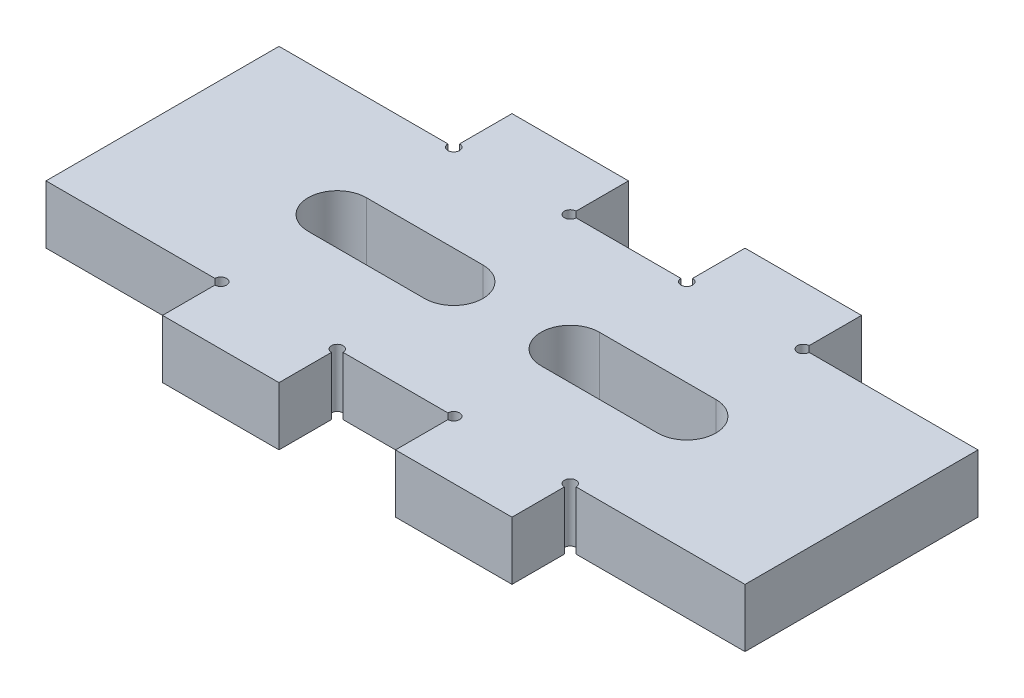
from build123d import *

# Parameters (mm, degrees)
BOSS_EXTRUDE1_DEPTH = 6.35
CUT_EXTRUDE1_REACH  = 45.068
SKETCH2_R           = 3.175
CUT_EXTRUDE2_START  = -6.35
SKETCH4_R           = 0.635
CUT_EXTRUDE2_DEPTH  = 6.35
CUT_EXTRUDE3_START  = -6.35
CUT_EXTRUDE3_DEPTH  = 6.35


with BuildPart() as part:
    # Sketch1 → Boss-Extrude1 (new body)
    with BuildSketch(Plane(origin=(0, 0, 0), x_dir=(1, 0, 0), z_dir=(0, 1, 0))):
        Polygon((-19.05, 12.7), (-19.05, 19.05), (-6.35, 19.05), (-6.35, 12.7), (6.35, 12.7), (6.35, 19.05), (19.05, 19.05), (19.05, 12.7), (38.1, 12.7), (38.1, -12.7), (19.05, -12.7), (19.05, -19.05), (6.35, -19.05), (6.35, -12.7), (-6.35, -12.7), (-6.35, -19.05), (-19.05, -19.05), (-19.05, -12.7), (-38.1, -12.7), (-38.1, 12.7), align=None)
    extrude(amount=BOSS_EXTRUDE1_DEPTH)

    # Sketch2 → Cut-Extrude1 (cut, up to next)
    with BuildSketch(Plane(origin=(0, 6.35, 0), x_dir=(1, 0, 0), z_dir=(0, 1, 0)), mode=Mode.PRIVATE) as cut_extrude1_sk1:
        with Locations(Location((-12.7, 0, 0), (0, 0, 270))):
            Circle(SKETCH2_R)
    cut_extrude1_tool1 = extrude(cut_extrude1_sk1.sketch, amount=-CUT_EXTRUDE1_REACH, mode=Mode.PRIVATE) & part.part
    # Sketch2 → Cut-Extrude1 (cut, up to next)
    with BuildSketch(Plane(origin=(0, 6.35, 0), x_dir=(1, 0, 0), z_dir=(0, 1, 0)), mode=Mode.PRIVATE) as cut_extrude1_sk2:
        with Locations(Location((12.7, 0, 0), (0, 0, 270))):
            Circle(SKETCH2_R)
    cut_extrude1_tool2 = extrude(cut_extrude1_sk2.sketch, amount=-CUT_EXTRUDE1_REACH, mode=Mode.PRIVATE) & part.part
    add(cut_extrude1_tool1.solids().sort_by_distance((-12.7, 6.35, 0))[0], mode=Mode.SUBTRACT)
    add(cut_extrude1_tool2.solids().sort_by_distance((12.7, 6.35, 0))[0], mode=Mode.SUBTRACT)

    # Sketch4 → Cut-Extrude2 (cut)
    with BuildSketch(Plane(origin=(0, 6.35, 0), x_dir=(1, 0, 0), z_dir=(0, 1, 0)).offset(CUT_EXTRUDE2_START)):
        with Locations((-19.05, 12.7)):
            Circle(SKETCH4_R)
    cut_extrude2 = extrude(amount=CUT_EXTRUDE2_DEPTH, mode=Mode.SUBTRACT)

    # Sketch-Pattern1: Cut-Extrude2 at 7 more places
    with Locations((12.7, 0, 0), (25.4, 0, 0), (38.1, 0, 0), (38.1, 0, 25.4), (25.4, 0, 25.4), (12.7, 0, 25.4), (0, 0, 25.4)):
        add(cut_extrude2, mode=Mode.SUBTRACT)

    # Sketch5 → Cut-Extrude3 (cut)
    with BuildSketch(Plane(origin=(0, 6.35, 0), x_dir=(1, 0, 0), z_dir=(0, 1, 0)).offset(CUT_EXTRUDE3_START)):
        with BuildLine():
            Line((-19.05, 3.175), (-6.35, 3.175))
            ThreePointArc((-6.35, 3.175), (-3.175, 0), (-6.35, -3.175))
            Line((-6.35, -3.175), (-19.05, -3.175))
            ThreePointArc((-19.05, -3.175), (-22.225, 0), (-19.05, 3.175))
        make_face()
        with BuildLine():
            Line((19.05, 3.175), (6.35, 3.175))
            ThreePointArc((6.35, 3.175), (3.175, 0), (6.35, -3.175))
            Line((6.35, -3.175), (19.05, -3.175))
            ThreePointArc((19.05, -3.175), (22.225, 0), (19.05, 3.175))
        make_face()
    extrude(amount=CUT_EXTRUDE3_DEPTH, mode=Mode.SUBTRACT)


solid = part.part
